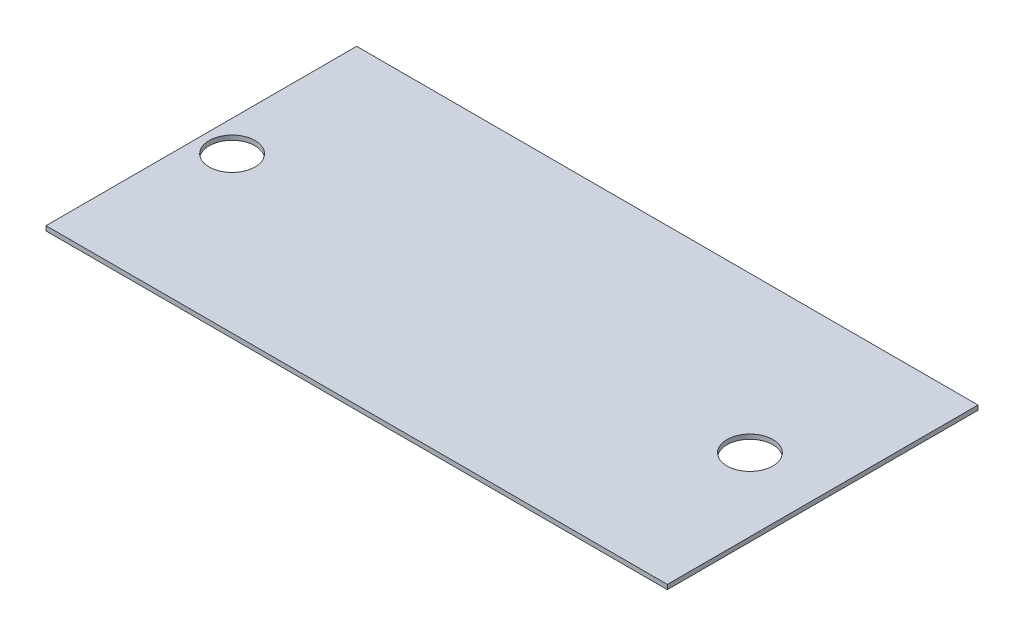
from build123d import *

# Parameters (mm, degrees)
SKETCH1_W           = 406.4
SKETCH1_H           = 203.2
BOSS_EXTRUDE1_DEPTH = 3
SKETCH2_R           = 15
CUT_EXTRUDE1_DEPTH  = 4


with BuildPart() as part:
    # Sketch1 → Boss-Extrude1 (new body)
    with BuildSketch(Plane(origin=(0, 0, 0), x_dir=(1, 0, 0), z_dir=(0, 1, 0))):
        with Locations((203.2, 101.6)):
            Rectangle(SKETCH1_W, SKETCH1_H)
    extrude(amount=BOSS_EXTRUDE1_DEPTH)

    # Sketch2 → Cut-Extrude1 (cut, through all)
    with BuildSketch(Plane(origin=(0, 3, 0), x_dir=(1, 0, 0), z_dir=(0, 1, 0))):
        with Locations((20.122810709, 101.6)):
            Circle(SKETCH2_R)
        with Locations((358.831003767, 101.6)):
            Circle(SKETCH2_R)
    extrude(amount=-CUT_EXTRUDE1_DEPTH, mode=Mode.SUBTRACT)


solid = part.part
